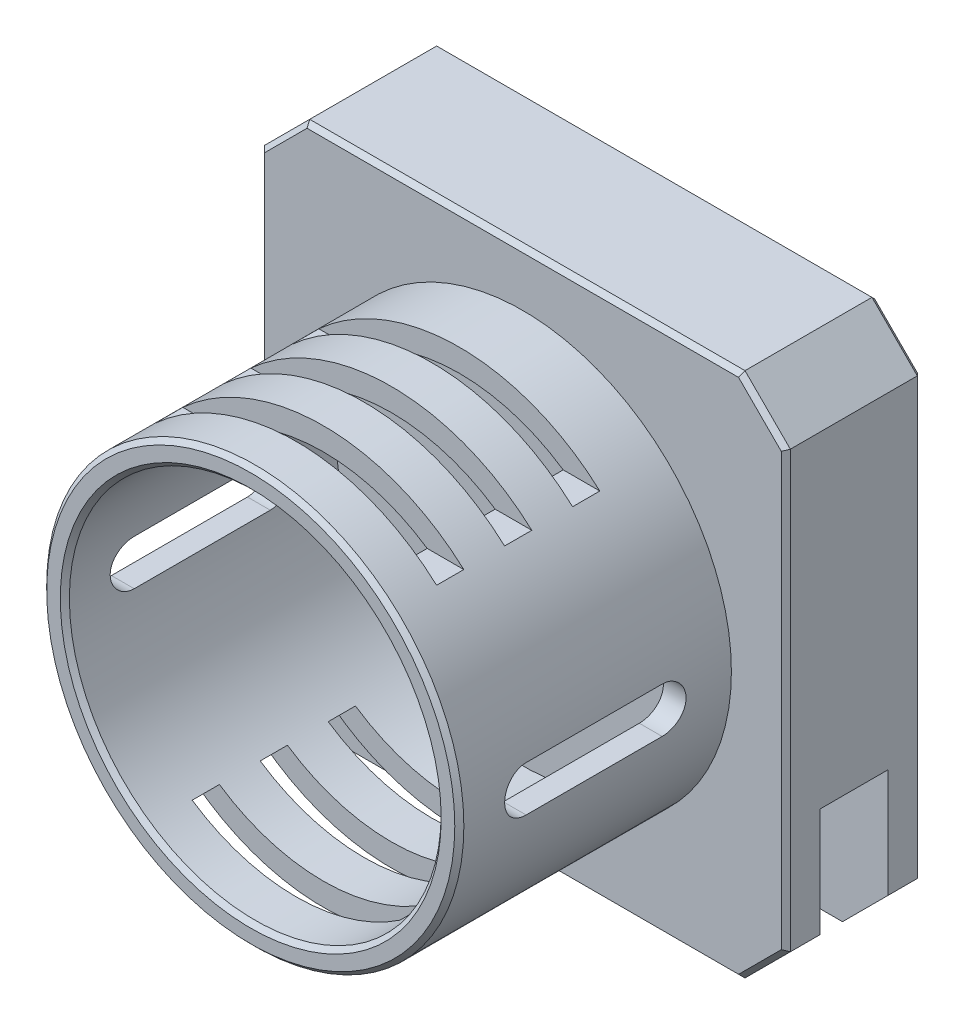
from build123d import *

# Parameters (mm, degrees)
SKIZZE3_W                       = 58
SKIZZE3_H                       = 58
AUFSATZ_LINEAR_AUSTRAGEN1_DEPTH = 15
SKIZZE4_R                       = 7.5
AUFSATZ_LINEAR_AUSTRAGEN2_DEPTH = 2
FASE1_SIZE                      = 5
SKIZZE5_R                       = 23
SKIZZE5_R_2                     = 20.5
AUFSATZ_LINEAR_AUSTRAGEN3_DEPTH = 30
SKIZZE6_W                       = 3
SKIZZE6_H                       = 39.520504732
SCHNITT_LINEAR_AUSTRAGEN1_DEPTH = 6
SKIZZE7_W                       = 3
SKIZZE7_H                       = 35.12933754
SCHNITT_LINEAR_AUSTRAGEN2_DEPTH = 6
SCHNITT_LINEAR_AUSTRAGEN3_DEPTH = 53
FASE2_SIZE                      = 0.5
FASE3_SIZE                      = 0.5
SKIZZE10_W                      = 58.775237502
SKIZZE10_H                      = 7.5
SCHNITT_LINEAR_AUSTRAGEN5_DEPTH = 17


with BuildPart() as part:
    # Skizze3 → Aufsatz-Linear austragen1 (new body)
    with BuildSketch(Plane.XY):
        Rectangle(SKIZZE3_W, SKIZZE3_H)
    extrude(amount=AUFSATZ_LINEAR_AUSTRAGEN1_DEPTH)

    # Skizze4 → Aufsatz-Linear austragen2 (add)
    with BuildSketch(Plane(origin=(0, 0, 0), x_dir=(-1, 0, 0), z_dir=(0, 0, -1))):
        with Locations(Location((0, 19, 0), (0, 0, 180))):  # turned: the seam where the file's is
            Circle(SKIZZE4_R)
        with Locations(Location((19, -19, 0), (0, 0, 180))):  # turned: the seam where the file's is
            Circle(SKIZZE4_R)
        with Locations(Location((-19, -19, 0), (0, 0, 180))):  # turned: the seam where the file's is
            Circle(SKIZZE4_R)
    extrude(amount=AUFSATZ_LINEAR_AUSTRAGEN2_DEPTH)

    # Fase1
    fase1_edges = [part.edges().sort_by_distance(p)[0] for p in [
        (29, -29, 7.5),
        (-29, -29, 7.5),
        (-29, 29, 7.5),
        (29, 29, 7.5),
    ]]
    chamfer(fase1_edges, length=FASE1_SIZE)

    # Skizze5 → Aufsatz-Linear austragen3 (add)
    with BuildSketch(Plane.XY.offset(15)):
        Circle(SKIZZE5_R)
        Circle(SKIZZE5_R_2, mode=Mode.SUBTRACT)
    extrude(amount=AUFSATZ_LINEAR_AUSTRAGEN3_DEPTH)

    # Skizze6 → Schnitt-Linear austragen1 (cut)
    with BuildSketch(Plane(origin=(0, -23, 0), x_dir=(0, 0, -1), z_dir=(0, -1, 0))):
        with Locations((-23.5, 0)):
            Rectangle(SKIZZE6_W, SKIZZE6_H)
        with Locations((-31, 0)):
            Rectangle(SKIZZE6_W, SKIZZE6_H)
        with Locations((-38.5, 0)):
            Rectangle(SKIZZE6_W, SKIZZE6_H)
    extrude(amount=-SCHNITT_LINEAR_AUSTRAGEN1_DEPTH, mode=Mode.SUBTRACT)

    # Skizze7 → Schnitt-Linear austragen2 (cut)
    with BuildSketch(Plane(origin=(0, 23, 0), x_dir=(0, 0, -1), z_dir=(0, 1, 0))):
        with Locations((-23.5, 0)):
            Rectangle(SKIZZE7_W, SKIZZE7_H)
        with Locations((-31, 0)):
            Rectangle(SKIZZE7_W, SKIZZE7_H)
        with Locations((-38.5, 0)):
            Rectangle(SKIZZE7_W, SKIZZE7_H)
    extrude(amount=-SCHNITT_LINEAR_AUSTRAGEN2_DEPTH, mode=Mode.SUBTRACT)

    # Skizze8 → Schnitt-Linear austragen3 (cut, through all)
    with BuildSketch(Plane(origin=(23, 0, 0), x_dir=(0, 0, -1), z_dir=(1, 0, 0))):
        with BuildLine():
            Line((-37.5, 2.5), (-22.5, 2.5))
            ThreePointArc((-22.5, 2.5), (-20, 0), (-22.5, -2.5))
            Line((-22.5, -2.5), (-37.5, -2.5))
            ThreePointArc((-37.5, -2.5), (-40, 0), (-37.5, 2.5))
        make_face()
    extrude(amount=-SCHNITT_LINEAR_AUSTRAGEN3_DEPTH, mode=Mode.SUBTRACT)

    # Fase2
    fase2_edges = [part.edges().sort_by_distance(p)[0] for p in [
        (-7.5, 19, -2),
        (-26.5, -19, -2),
        (11.5, -19, -2),
        (-23, 0, 45),
        (-20.5, 0, 45),
    ]]
    chamfer(fase2_edges, length=FASE2_SIZE)

    # Fase3
    fase3_edges = [part.edges().sort_by_distance(p)[0] for p in [
        (0, -29, 0),
        (0, -29, 15),
        (29, 0, 0),
        (-29, 0, 0),
        (0, 29, 0),
        (-26.5, 26.5, 0),
        (26.5, 26.5, 0),
        (26.5, -26.5, 0),
        (-26.5, -26.5, 0),
        (-29, 0, 15),
        (29, 0, 15),
        (0, 29, 15),
        (-26.5, 26.5, 15),
        (26.5, 26.5, 15),
        (26.5, -26.5, 15),
        (-26.5, -26.5, 15),
    ]]
    chamfer(fase3_edges, length=FASE3_SIZE)

    # Skizze10 → Schnitt-Linear austragen5 (cut)
    with BuildSketch(Plane.XZ.offset(29)):
        with Locations((0, 7.5)):
            Rectangle(SKIZZE10_W, SKIZZE10_H)
    extrude(amount=-SCHNITT_LINEAR_AUSTRAGEN5_DEPTH, mode=Mode.SUBTRACT)


solid = part.part
